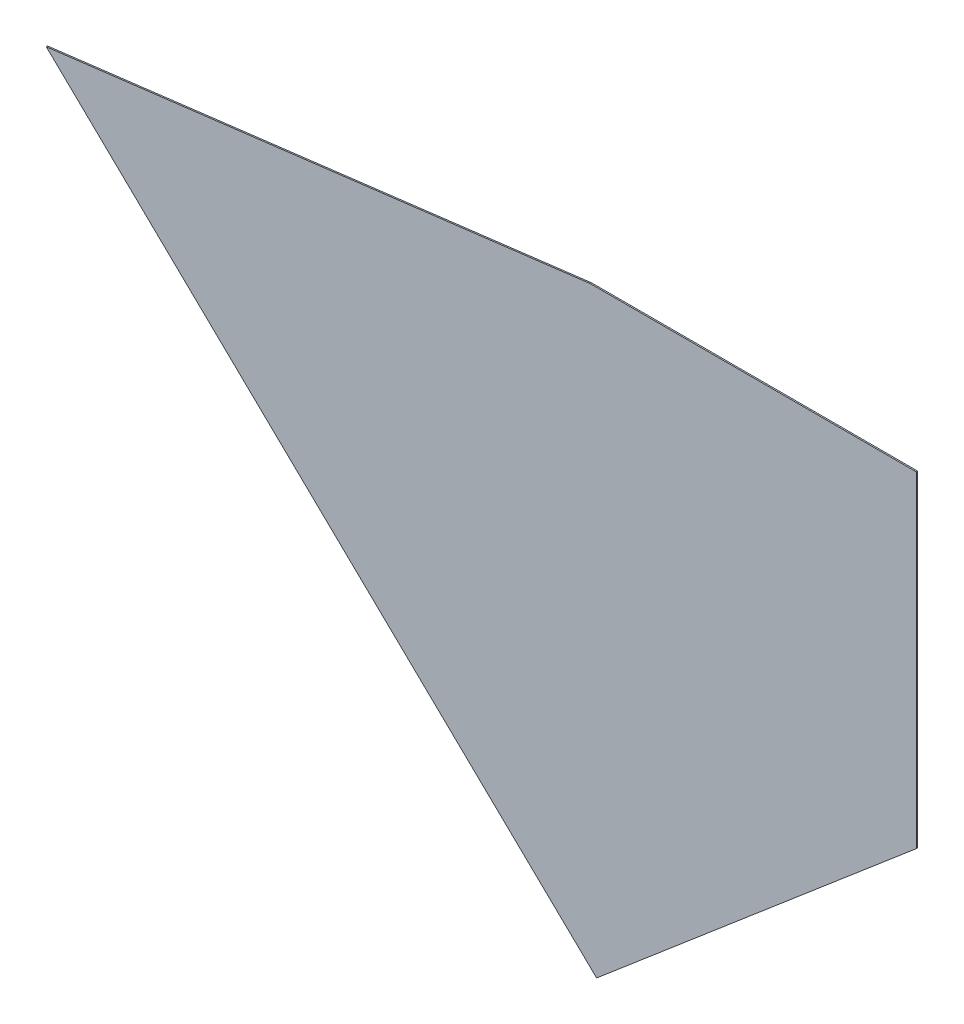
from build123d import *

# Parameters (mm, degrees)
BOSS_EXTRUDE1_DEPTH = 6.35


with BuildPart() as part:
    # Sketch1 → Boss-Extrude1 (new body)
    with BuildSketch(Plane.XY):
        Polygon((-762, 762), (762, 762), (762, -762), (-731.52, -2032), (-3302, 449.58), align=None)
    extrude(amount=BOSS_EXTRUDE1_DEPTH)


solid = part.part
